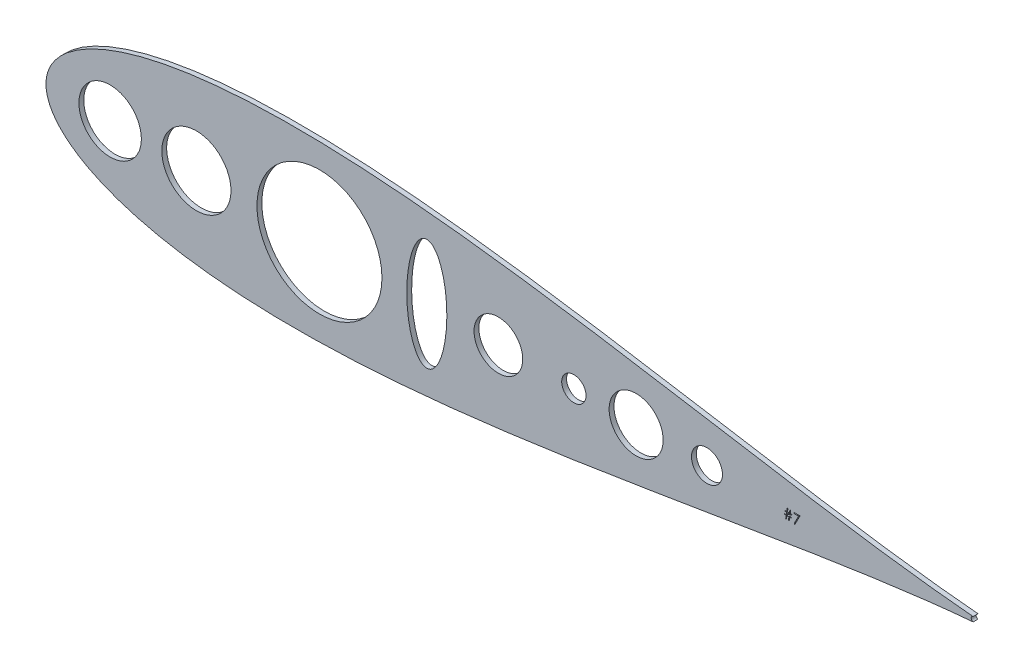
from build123d import *

# Parameters (mm, degrees)
SKETCH2_R           = 16.284851911
SKETCH2_R_2         = 8.086464582
SKETCH2_R_3         = 14.095693802
SKETCH2_R_4         = 6.35
SKETCH2_R_5         = 12.7
SKETCH2_R_6         = 32.589606416
SKETCH2_R_7         = 18.034
SKETCH2_RX          = 29.101247041
SKETCH2_RY          = 10.44471683
BOSS_EXTRUDE1_DEPTH = 2.54


with BuildPart() as part:
    # Sketch2 → Boss-Extrude1 (new body)
    with BuildSketch(Plane.XY):
        with BuildLine():
            ThreePointArc((766.974707566, 536.0675915), (765.977629702, 534.849381698), (766.971711663, 533.628725955))
            add(Edge.make_bspline(
                [(766.974707566, 536.0675915), (766.697054085, 536.090852324), (763.873123694, 536.329594825), (758.201482231, 536.853813505), (749.6175132, 537.746772238), (740.100244032, 538.842519253), (729.685451337, 540.147623314), (718.421724616, 541.663413247), (706.357773545, 543.386490706), (693.545839391, 545.307955256), (680.040327856, 547.414137956), (665.897819132, 549.686233311), (651.17675853, 552.100773697), (635.937286586, 554.629922582), (620.241044202, 557.241756825), (604.151069344, 559.900838292), (587.731693374, 562.568639299), (571.048486813, 565.204174172), (554.168223798, 567.764551636), (537.158879427, 570.205736164), (520.089621791, 572.483106682), (503.030828763, 574.552251895), (486.054099694, 576.369608591), (469.232266346, 577.893230912), (452.639385938, 579.08340224), (436.35073971, 579.903377869), (420.442816542, 580.320076354), (404.993286939, 580.304606106), (390.081029155, 579.832425784), (375.786130426, 578.885048081), (362.190119693, 577.44873509), (349.376096715, 575.517012434), (337.429508833, 573.089202487), (326.438731105, 570.173429157), (316.496679793, 566.786781081), (307.702536547, 562.959433862), (300.163095536, 558.742070099), (293.990992596, 554.220272545), (289.290158899, 549.541729576), (286.107619349, 544.953811108), (284.332946603, 540.814596473), (283.616300203, 537.49417308), (283.453077529, 534.848284229), (283.616300203, 532.202395378), (284.332946603, 528.881971984), (286.107619349, 524.74275735), (289.290158899, 520.154838882), (293.990992596, 515.476295913), (300.163095536, 510.954498359), (307.702536547, 506.737134595), (316.496679793, 502.909787376), (326.438731105, 499.5231393), (337.429508833, 496.607365971), (349.376096715, 494.179556024), (362.190119693, 492.247833368), (375.786130426, 490.811520377), (390.081029155, 489.864142673), (404.993286939, 489.391962352), (420.442816542, 489.376492104), (436.35073971, 489.793190588), (452.639385938, 490.613166218), (469.232266346, 491.803337546), (486.054099694, 493.326959867), (503.030828763, 495.144316563), (520.089621791, 497.213461776), (537.158879427, 499.490832294), (554.168223798, 501.932016822), (571.048486813, 504.492394286), (587.731693374, 507.127929158), (604.151069344, 509.795730166), (620.241044202, 512.454811633), (635.937286586, 515.066645875), (651.17675853, 517.59579476), (665.897819132, 520.010335147), (680.040327856, 522.282430502), (693.545839391, 524.388613201), (706.357773545, 526.310077751), (718.421724616, 528.03315521), (729.685451337, 529.548945144), (740.100244032, 530.854049204), (749.6175132, 531.94979622), (758.201482231, 532.842754952), (763.872130469, 533.366881831), (766.695057272, 533.605547314), (766.971711663, 533.628725955)],
                knots=[0.020477074, 0.020477074, 0.020477074, 0.020477074, 0.021270888, 0.028552555, 0.036780684, 0.045920102, 0.055931764, 0.066772884, 0.07839713, 0.090754827, 0.103793165, 0.117456432, 0.131686226, 0.146421738, 0.161599998, 0.177156133, 0.193023668, 0.209134786, 0.225420633, 0.241811602, 0.258237647, 0.274628557, 0.290914287, 0.307025229, 0.322892517, 0.338448342, 0.353626207, 0.368361232, 0.382590428, 0.396252961, 0.409290412, 0.42164701, 0.433269881, 0.444109249, 0.45411864, 0.463255055, 0.471479114, 0.478755289, 0.485052318, 0.490344026, 0.494609833, 0.497833231, 0.5, 0.502166769, 0.505390167, 0.509655974, 0.514947682, 0.521244711, 0.528520886, 0.536744945, 0.54588136, 0.555890751, 0.566730119, 0.57835299, 0.590709588, 0.603747039, 0.617409572, 0.631638768, 0.646373793, 0.661551658, 0.677107483, 0.692974771, 0.709085713, 0.725371443, 0.741762353, 0.758188398, 0.774579367, 0.790865214, 0.806976332, 0.822843867, 0.838400002, 0.853578262, 0.868313774, 0.882543568, 0.896206835, 0.909245173, 0.92160287, 0.933227116, 0.944068236, 0.954079898, 0.963219316, 0.971447445, 0.978729112, 0.979520071, 0.979520071, 0.979520071, 0.979520071], degree=3))
        make_face()
        with Locations((316.941522214, 534.848284226)):
            Circle(SKETCH2_R, mode=Mode.SUBTRACT)
        with Locations((628.18314295, 534.848284226)):
            Circle(SKETCH2_R_2, mode=Mode.SUBTRACT)
        with Locations((591.243806812, 534.848284226)):
            Circle(SKETCH2_R_3, mode=Mode.SUBTRACT)
        with Locations((558.767297683, 534.848284226)):
            Circle(SKETCH2_R_4, mode=Mode.SUBTRACT)
        with Locations((519.397297683, 534.848284226)):
            Circle(SKETCH2_R_5, mode=Mode.SUBTRACT)
        with Locations((426.103245257, 534.848284226)):
            Circle(SKETCH2_R_6, mode=Mode.SUBTRACT)
        with Locations((361.917297683, 534.848284226)):
            Circle(SKETCH2_R_7, mode=Mode.SUBTRACT)
        with Locations(Location((482.088218682, 534.848284226), (0, 0, -90))):
            Ellipse(SKETCH2_RX, SKETCH2_RY, mode=Mode.SUBTRACT)
        Polygon((672.286556039, 533.388506256), (672.286556039, 533.062865231), (671.315738727, 533.062865231), (671.052173026, 531.304403693), (670.658350903, 531.304403693), (670.921916614, 533.062865231), (669.882918215, 533.062865231), (669.619352504, 531.304403693), (669.225530391, 531.304403693), (669.489096102, 533.062865231), (668.639376551, 533.062865231), (668.639376551, 533.388506256), (669.537942252, 533.388506256), (669.713991928, 534.560813945), (668.769632953, 534.560813945), (668.769632953, 534.88645497), (669.762838089, 534.88645497), (670.007068853, 536.514660095), (670.39987334, 536.514660095), (670.155642577, 534.88645497), (671.195658602, 534.88645497), (671.439889365, 536.514660095), (671.832693853, 536.514660095), (671.588463089, 534.88645497), (672.416812441, 534.88645497), (672.416812441, 534.560813945), (671.539616928, 534.560813945), (671.364584878, 533.388506256), align=None, mode=Mode.SUBTRACT)
        Polygon((673.589120139, 536.384403693), (676.715273978, 536.384403693), (674.045017577, 531.174147281), (673.651195453, 531.390902083), (675.943911803, 535.863378045), (673.589120139, 535.863378045), align=None, mode=Mode.SUBTRACT)
    extrude(amount=BOSS_EXTRUDE1_DEPTH)


solid = part.part
